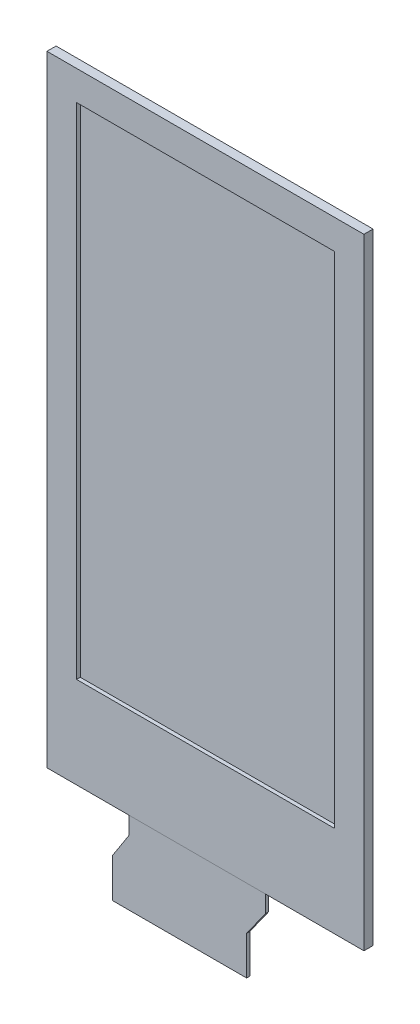
from build123d import *

# Parameters (mm, degrees)
MAIN_FEATURES_SKETCH_W = 24
MAIN_FEATURES_SKETCH_H = 46.5
DISPLAY_DEPTH          = 0.5
SKETCH1_3_W            = 24
SKETCH1_3_H            = 46.5
BEZEL_DEPTH            = 0.85
CABLE_START            = 0.5
CABLE_DEPTH            = 0.3


with BuildPart() as part:
    # main_features_sketch → display (new body)
    with BuildSketch(Plane.XY):
        Rectangle(MAIN_FEATURES_SKETCH_W, MAIN_FEATURES_SKETCH_H)
    extrude(amount=DISPLAY_DEPTH)


with BuildPart() as body_2:
    # Sketch1_3 → bezel (new body)
    with BuildSketch(Plane.XY):
        Polygon((-14.752, -31.75), (-7.152, -31.75), (5.518182239, -31.75), (14.748, -31.75), (14.748, 26), (-14.752, 26), align=None)
        Rectangle(SKETCH1_3_W, SKETCH1_3_H, mode=Mode.SUBTRACT)
    extrude(amount=BEZEL_DEPTH)


with BuildPart() as body_3:
    # Sketch1_4 → cable (new body)
    with BuildSketch(Plane.XY.offset(CABLE_START)):
        Polygon((5.518182239, -31.75), (-7.152, -31.75), (-7.152, -33.406095238), (-8.722, -35.849), (-8.722, -39.45), (3.778, -39.45), (3.778, -35.849), (5.518182239, -33.406095238), align=None)
    extrude(amount=CABLE_DEPTH)


solid = Compound([part.part, body_2.part, body_3.part])
